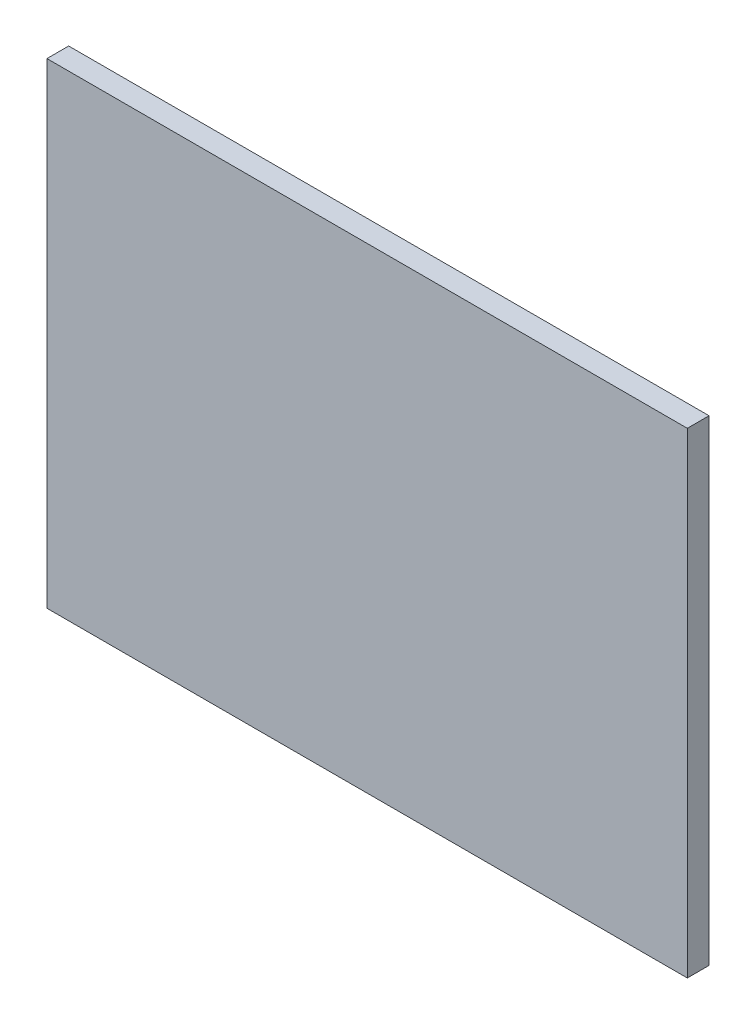
from build123d import *

# Parameters (mm, degrees)
SKETCH1_W           = 530
SKETCH1_H           = 394
BOSS_EXTRUDE1_DEPTH = 18


with BuildPart() as part:
    # Sketch1 → Boss-Extrude1 (new body)
    with BuildSketch(Plane.XY):
        Rectangle(SKETCH1_W, SKETCH1_H)
    extrude(amount=BOSS_EXTRUDE1_DEPTH)


solid = part.part
